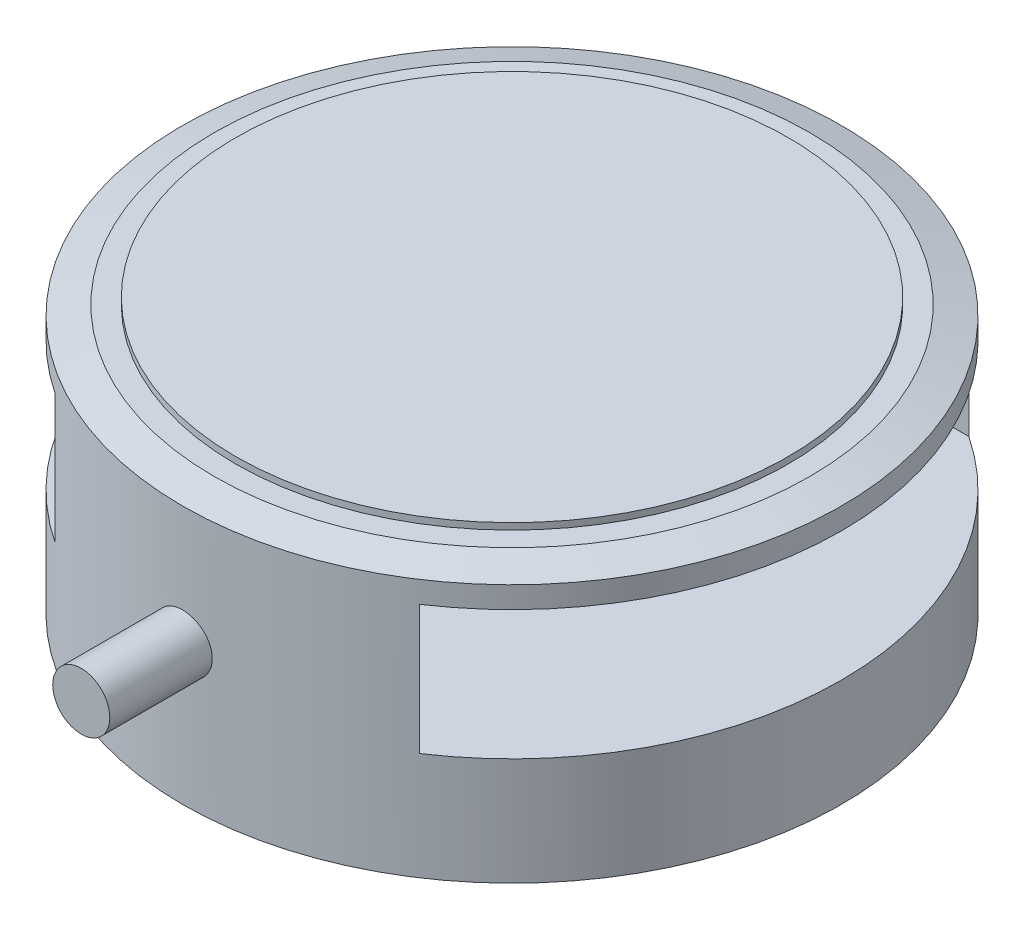
from build123d import *

# Parameters (mm, degrees)
SKETCH_1_R               = 30.6
EXTRUDE_1_DEPTH          = 24
SKETCH_3_R               = 30.6
EXTRUDE_2_DEPTH          = 0.9
EXTRUDE_2_TAPER          = 73
SKETCH_4_R               = 25.656232643
EXTRUDE_3_DEPTH          = 0.6
SKETCH_5_W               = 51
SKETCH_5_H               = 12
CUT_EXTRUDE_1_DEPTH      = 31.6000001
CUT_EXTRUDE_1_DEPTH_BACK = 31.6000001
SKETCH_6_R               = 2.65
EXTRUDE_4_DEPTH          = 13


with BuildPart() as part:
    # 草图1 → 凸台-拉伸1 (new body)
    with BuildSketch(Plane(origin=(0, 0, 0), x_dir=(1, 0, 0), z_dir=(0, 1, 0))):
        Circle(SKETCH_1_R)
    extrude(amount=EXTRUDE_1_DEPTH)

    # 草图3 → 凸台-拉伸2 (add)
    with BuildSketch(Plane(origin=(0, 24, 0), x_dir=(1, 0, 0), z_dir=(0, 1, 0))):
        Circle(SKETCH_3_R)
    extrude(amount=EXTRUDE_2_DEPTH, taper=EXTRUDE_2_TAPER)

    # 草图4 → 凸台-拉伸3 (add)
    with BuildSketch(Plane(origin=(0, 24.9, 0), x_dir=(1, 0, 0), z_dir=(0, 1, 0))):
        Circle(SKETCH_4_R)
    extrude(amount=EXTRUDE_3_DEPTH)

    # 草图5 → 切除-拉伸1 (cut, two sides)
    with BuildSketch(Plane(origin=(0, 0, 0), x_dir=(0, 0, -1), z_dir=(1, 0, 0))) as cut_extrude_1_sk:
        with Locations((0, 16)):
            Rectangle(SKETCH_5_W, SKETCH_5_H)
    extrude(amount=CUT_EXTRUDE_1_DEPTH, mode=Mode.SUBTRACT)
    extrude(cut_extrude_1_sk.sketch, amount=-CUT_EXTRUDE_1_DEPTH_BACK, mode=Mode.SUBTRACT)

    # 草图6 → 凸台-拉伸4 (add)
    with BuildSketch(Plane.XY.offset(27)):
        with Locations((0, 13)):
            Circle(SKETCH_6_R)
    extrude(amount=EXTRUDE_4_DEPTH)


solid = part.part
